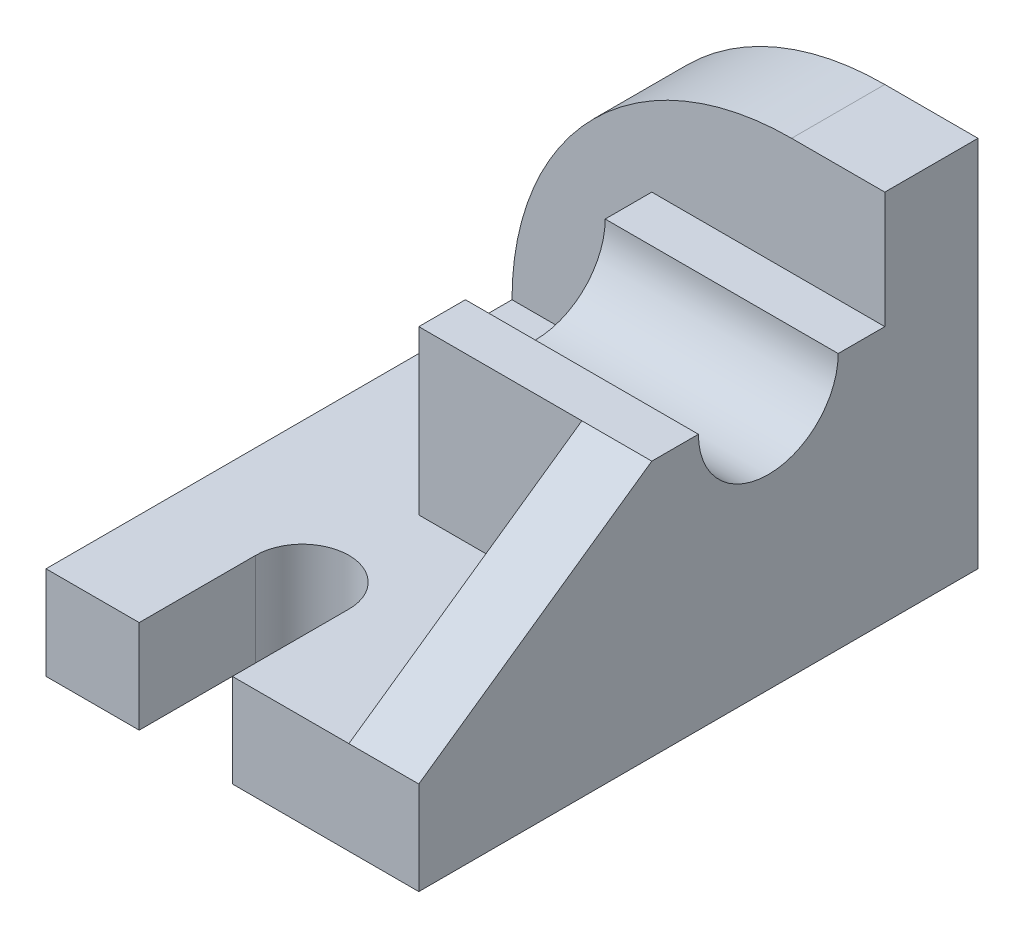
from build123d import *

# Parameters (mm, degrees)
SKETCH2_W           = 64
SKETCH2_H           = 96
BOSS_EXTRUDE1_DEPTH = 16
SKETCH3_W           = 64
SKETCH3_H           = 16
BOSS_EXTRUDE3_DEPTH = 48
FILLET3_R           = 48
SKETCH5_W           = 40
SKETCH5_H           = 40
BOSS_EXTRUDE4_DEPTH = 28
SKETCH6_R           = 12
CUT_EXTRUDE1_DEPTH  = 63
SKETCH7_W           = 12.002152701
SKETCH7_H           = 40
BOSS_EXTRUDE6_DEPTH = 28
CUT_EXTRUDE2_DEPTH  = 30
CUT_EXTRUDE3_DEPTH  = 17


with BuildPart() as part:
    # Sketch2 → Boss-Extrude1 (new body)
    with BuildSketch(Plane(origin=(0, 0, 0), x_dir=(1, 0, 0), z_dir=(0, 1, 0))):
        Rectangle(SKETCH2_W, SKETCH2_H)
    extrude(amount=BOSS_EXTRUDE1_DEPTH)

    # Sketch3 → Boss-Extrude3 (add)
    with BuildSketch(Plane(origin=(0, 16, 0), x_dir=(1, 0, 0), z_dir=(0, 1, 0))):
        with Locations((0, 40)):
            Rectangle(SKETCH3_W, SKETCH3_H)
    extrude(amount=BOSS_EXTRUDE3_DEPTH)

    # Fillet3
    fillet3_edges = [part.edges().sort_by_distance(p)[0] for p in [
        (-32, 64, -40),
    ]]
    fillet(fillet3_edges, radius=FILLET3_R)

    # Sketch5 → Boss-Extrude4 (add)
    with BuildSketch(Plane(origin=(0, 16, 0), x_dir=(1, 0, 0), z_dir=(0, 1, 0))):
        with Locations((12, 12)):
            Rectangle(SKETCH5_W, SKETCH5_H)
    extrude(amount=BOSS_EXTRUDE4_DEPTH)

    # Sketch6 → Cut-Extrude1 (cut)
    with BuildSketch(Plane.ZY.offset(8)):
        with Locations((-12, 44)):
            Circle(SKETCH6_R)
    extrude(amount=-CUT_EXTRUDE1_DEPTH, mode=Mode.SUBTRACT)

    # Sketch7 → Boss-Extrude6 (add)
    with BuildSketch(Plane(origin=(0, 16, 0), x_dir=(1, 0, 0), z_dir=(0, 1, 0))):
        with Locations((25.99892365, -28)):
            Rectangle(SKETCH7_W, SKETCH7_H)
    extrude(amount=BOSS_EXTRUDE6_DEPTH)

    # Sketch9 → Cut-Extrude2 (cut)
    with BuildSketch(Plane.ZY.offset(-19.997847299)):
        Polygon((8, 44), (48, 16), (48, 44), align=None)
    extrude(amount=-CUT_EXTRUDE2_DEPTH, mode=Mode.SUBTRACT)

    # Sketch10 → Cut-Extrude3 (cut, through all)
    with BuildSketch(Plane(origin=(0, 16, 0), x_dir=(1, 0, 0), z_dir=(0, 1, 0))):
        with BuildLine():
            Line((-16, -48), (-16, -28))
            ThreePointArc((-16, -28), (-8, -20), (0, -28))
            Line((0, -28), (0, -48))
            ThreePointArc((0, -48), (-8, -56), (-16, -48))
        make_face()
    extrude(amount=-CUT_EXTRUDE3_DEPTH, mode=Mode.SUBTRACT)


solid = part.part
